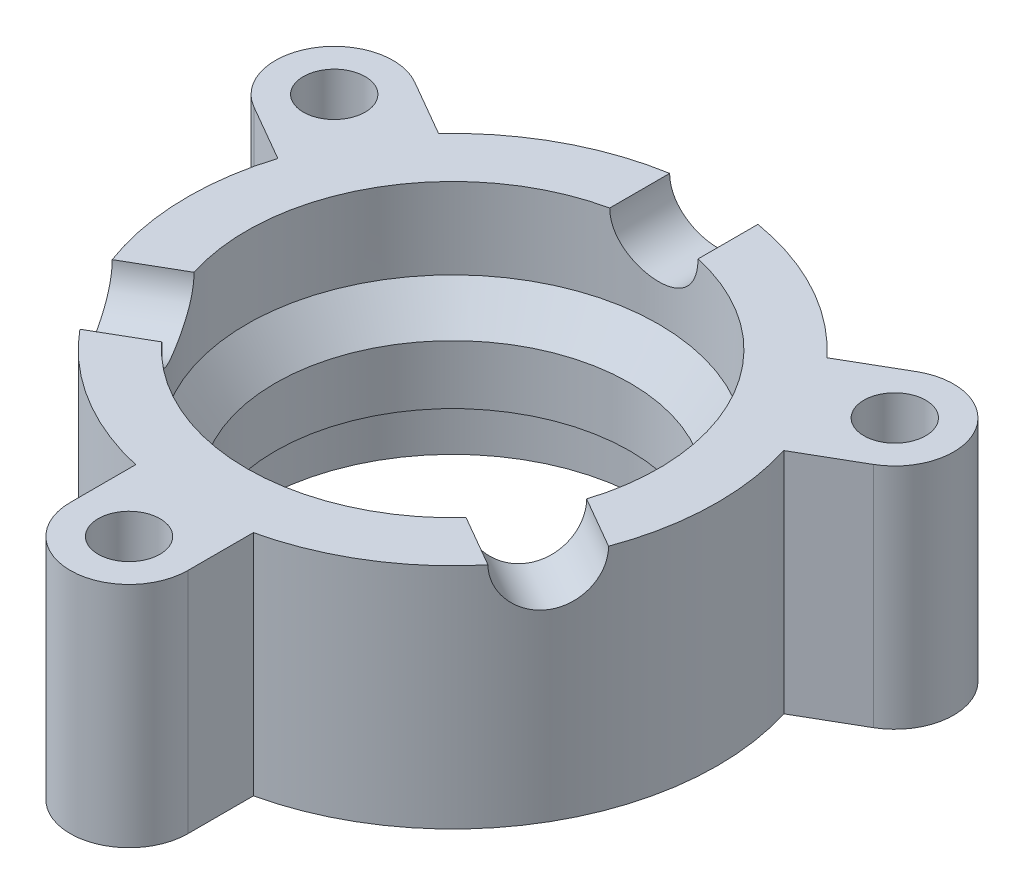
from build123d import *

# Parameters (mm, degrees)
SKETCH1_R           = 2.1
BOSS_EXTRUDE1_DEPTH = 15.5
SKETCH2_R           = 14
CUT_EXTRUDE1_DEPTH  = 16.5
CUT_EXTRUDE2_START  = -18
SKETCH4_R           = 3
CUT_EXTRUDE2_DEPTH  = 4.325206
CIRPATTERN1_COUNT   = 3


with BuildPart() as part:
    # Sketch1 → Boss-Extrude1 (new body)
    with BuildSketch(Plane(origin=(0, 0, 0), x_dir=(1, 0, 0), z_dir=(0, 1, 0))):
        with BuildLine():
            Line((-4, -17.549928775), (-4, -22))
            ThreePointArc((-4, -22), (0, -26), (4, -22))
            Line((4, -22), (4, -17.549928775))
            ThreePointArc((4, -17.549928775), (15.588457268, -9), (17.198684154, 5.310862772))
            Line((17.198684154, 5.310862772), (21.052558883, 7.535898385))
            ThreePointArc((21.052558883, 7.535898385), (22.516660498, 13), (17.052558883, 14.464101615))
            Line((17.052558883, 14.464101615), (13.198684154, 12.239066003))
            ThreePointArc((13.198684154, 12.239066003), (0, 18), (-13.198684154, 12.239066003))
            Line((-13.198684154, 12.239066003), (-17.052558883, 14.464101615))
            ThreePointArc((-17.052558883, 14.464101615), (-22.516660498, 13), (-21.052558883, 7.535898385))
            Line((-21.052558883, 7.535898385), (-17.198684154, 5.310862772))
            ThreePointArc((-17.198684154, 5.310862772), (-15.588457268, -9), (-4, -17.549928775))
        make_face()
        with Locations((0, -22)):
            Circle(SKETCH1_R, mode=Mode.SUBTRACT)
        with Locations((-19.052558883, 11)):
            Circle(SKETCH1_R, mode=Mode.SUBTRACT)
        with Locations((19.052558883, 11)):
            Circle(SKETCH1_R, mode=Mode.SUBTRACT)
    extrude(amount=BOSS_EXTRUDE1_DEPTH)

    # Sketch2 → Cut-Extrude1 (cut, through all)
    with BuildSketch(Plane(origin=(0, 15.5, 0), x_dir=(1, 0, 0), z_dir=(0, 1, 0))):
        Circle(SKETCH2_R)
    extrude(amount=-CUT_EXTRUDE1_DEPTH, mode=Mode.SUBTRACT)

    # Sketch3 → Revolve1 (revolve)
    with BuildSketch(Plane.XY):
        Polygon((14, 10), (12.058684154, 7.5), (12.058684154, 3.5), (13.198684154, 3.5), (13.198684154, 0), (14, 0), (14.499168446, 0), (14.499168446, 10), align=None)
    revolve(axis=Axis((0, 0, 0), (0, 1, 0)))

    # Sketch4 → Cut-Extrude2 (cut)
    with BuildSketch(Plane.XY.offset(CUT_EXTRUDE2_START)):
        with Locations((0, 15.5)):
            Circle(SKETCH4_R)
    cut_extrude2 = extrude(amount=CUT_EXTRUDE2_DEPTH, mode=Mode.SUBTRACT)

    # CirPattern1: Cut-Extrude2 ×3 about axis
    cirpattern1_axis = Axis((0, 0, 0), (0, 1, 0))
    for i in range(1, CIRPATTERN1_COUNT):
        add(cut_extrude2.rotate(cirpattern1_axis, i * 360 / CIRPATTERN1_COUNT), mode=Mode.SUBTRACT)


solid = part.part
